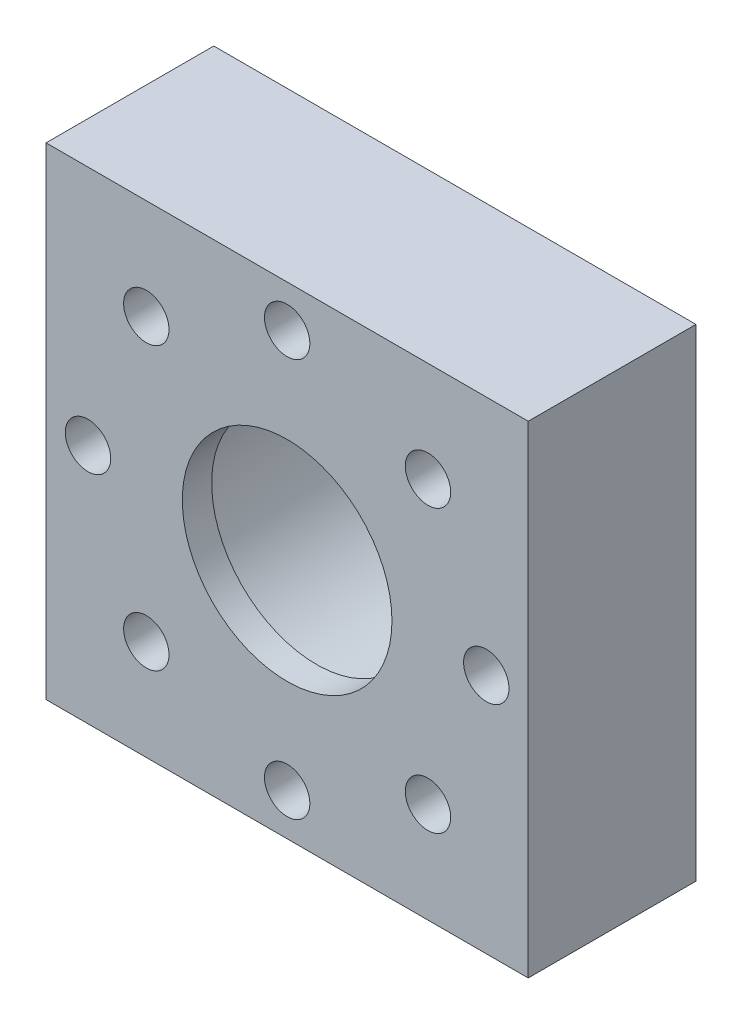
from build123d import *

# Parameters (mm, degrees)
SKETCH1_W                = 58.42
SKETCH1_H                = 58.42
BOSS_EXTRUDE1_DEPTH      = 20.32
M5_CLEARANCE_HOLE1_D     = 5.5
M5_CLEARANCE_HOLE1_DEPTH = 20.32
CIRPATTERN1_COUNT        = 8
SKETCH9_R                = 14.4907
SKETCH9_R_2              = 12.7
BOSS_EXTRUDE2_DEPTH      = 3.556


with BuildPart() as part:
    # Sketch1 → Boss-Extrude1 (new body)
    with BuildSketch(Plane.XY):
        Rectangle(SKETCH1_W, SKETCH1_H)
    extrude(amount=BOSS_EXTRUDE1_DEPTH)

    # Sketch7 → 1 NPT Tapped Hole2 (revolve, cut)
    with BuildSketch(Plane.YZ):
        Polygon((0, 0), (0, 20.32), (14.4907, 20.32), (14.4907, 16.764), (15.22797859, 16.764), (15.7299152, 0), align=None)
    revolve(axis=Axis((0, 0, -6.35), (0, 0, 1)), mode=Mode.SUBTRACT)

    # M5 Clearance Hole1
    with Locations(Plane(origin=(0, 0, 0), x_dir=(-1, 0, 0), z_dir=(0, 0, -1))):
        with Locations((0, 24.13)):
            m5_clearance_hole1 = Hole(M5_CLEARANCE_HOLE1_D / 2, depth=M5_CLEARANCE_HOLE1_DEPTH)

    # CirPattern1: M5 Clearance Hole1 ×8 about axis
    cirpattern1_axis = Axis((0, 0, 0), (0, 0, 1))
    for i in range(1, CIRPATTERN1_COUNT):
        add(m5_clearance_hole1.rotate(cirpattern1_axis, i * 360 / CIRPATTERN1_COUNT), mode=Mode.SUBTRACT)

    # Sketch9 → Boss-Extrude2 (add)
    with BuildSketch(Plane.XY.offset(20.32)):
        Circle(SKETCH9_R)
        Circle(SKETCH9_R_2, mode=Mode.SUBTRACT)
    extrude(amount=-BOSS_EXTRUDE2_DEPTH)


solid = part.part
